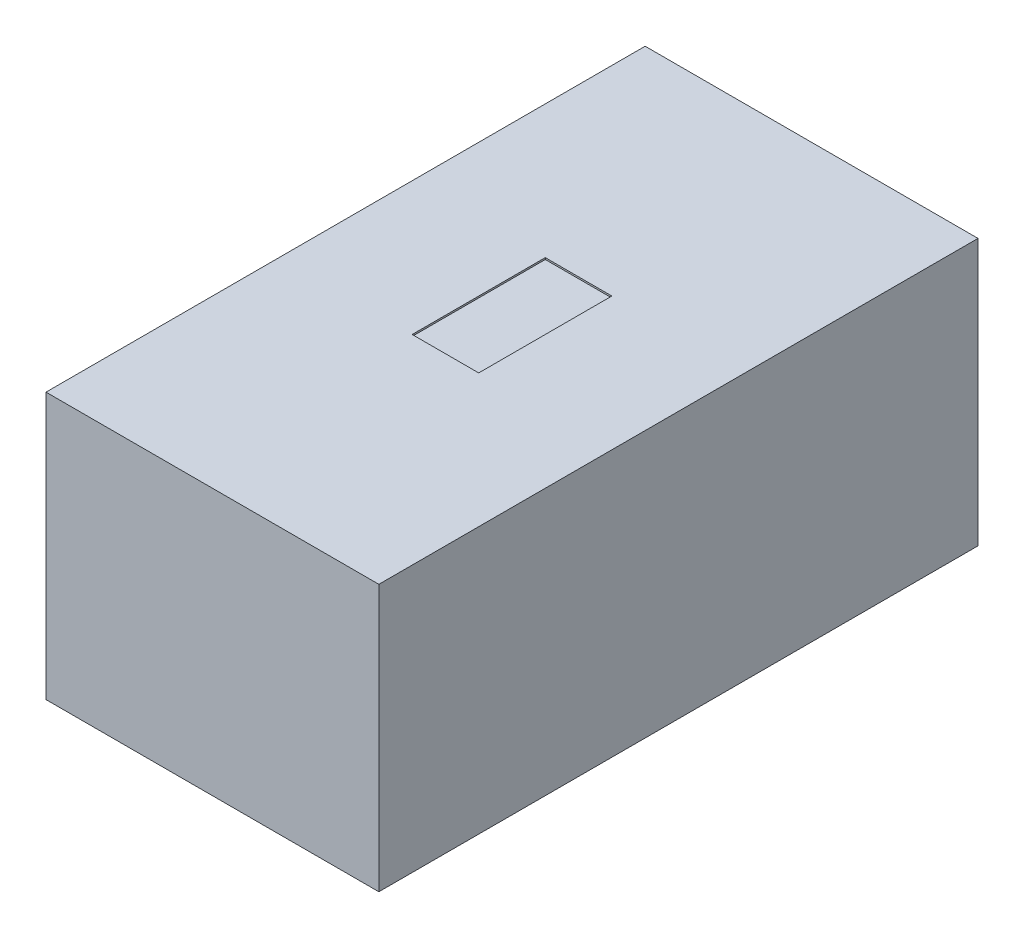
from build123d import *

# Parameters (mm, degrees)
PROFILES_W    = 1
PROFILES_H    = 1.8
PROFILE_DEPTH = 0.8
TOPCUTS_W     = 0.2
TOPCUTS_H     = 0.4
TOPCUT_DEPTH  = 0.005


with BuildPart() as part:
    # ProfileS → Profile (new body)
    with BuildSketch(Plane(origin=(0, 0, 0), x_dir=(1, 0, 0), z_dir=(0, 1, 0))):
        Rectangle(PROFILES_W, PROFILES_H)
    extrude(amount=PROFILE_DEPTH)

    # TopCutS → TopCut (cut)
    with BuildSketch(Plane(origin=(0, 0.8, 0), x_dir=(1, 0, 0), z_dir=(0, 1, 0))):
        Rectangle(TOPCUTS_W, TOPCUTS_H)
    extrude(amount=-TOPCUT_DEPTH, mode=Mode.SUBTRACT)


solid = part.part
